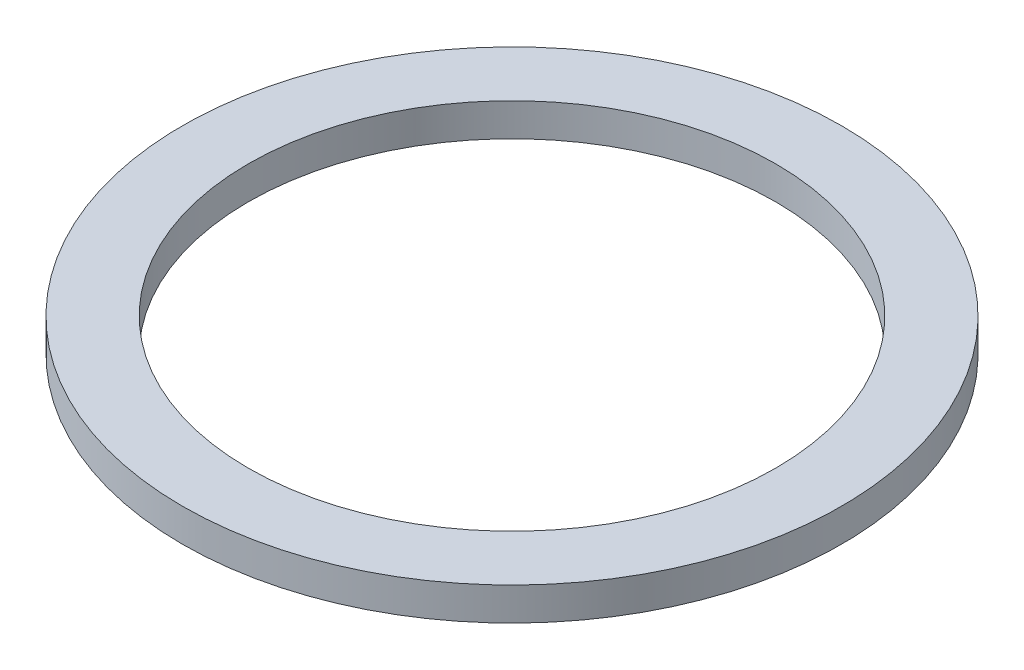
from build123d import *

# Parameters (mm, degrees)
SKETCH_1_R      = 1
SKETCH_1_R_2    = 0.8
EXTRUDE_1_DEPTH = 0.1


with BuildPart() as part:
    # 草图1 → 拉伸-薄壁1 (new body)
    with BuildSketch(Plane(origin=(0, 0, 0), x_dir=(1, 0, 0), z_dir=(0, 1, 0))):
        Circle(SKETCH_1_R)
        Circle(SKETCH_1_R_2, mode=Mode.SUBTRACT)
    extrude(amount=EXTRUDE_1_DEPTH)


solid = part.part
